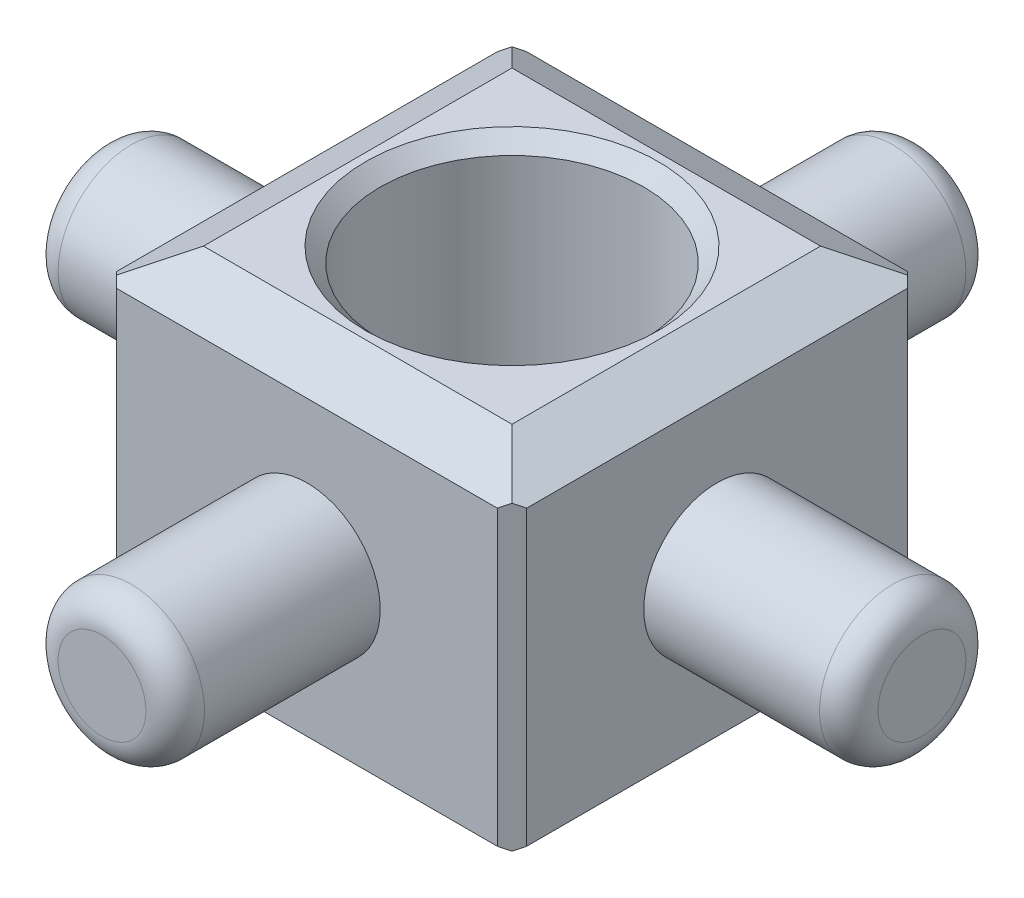
from build123d import *

# Parameters (mm, degrees)
SKETCH1_W                = 7
SKETCH1_H                = 7
EXTRUDE1_DEPTH           = 6
SKETCH2_R                = 2.25
CUT_EXTRUDE1_DEPTH       = 6
SKETCH3_R                = 1.25
EXTRUDE2_DEPTH           = 3.5
FILLET2_R                = 0.5
CIRPATTERN1_COUNT        = 4
FILLET2_OF_CIRPATTERN1_R = 0.5
CHAMFER1_SIZE            = 0.25
CHAMFER2_SIZE            = 0.5
CHAMFER2_SIZE2           = 0.866025404
CHAMFER2_PART_2_SIZE     = 0.5
CHAMFER2_PART_2_SIZE2    = 0.866025404
CHAMFER2_PART_3_SIZE     = 0.5
CHAMFER2_PART_3_SIZE2    = 0.866025404
CHAMFER2_PART_4_SIZE     = 0.5
CHAMFER2_PART_4_SIZE2    = 0.866025404


with BuildPart() as part:
    # Sketch1 → Extrude1 (new body)
    with BuildSketch(Plane(origin=(0, 0, 0), x_dir=(1, 0, 0), z_dir=(0, 1, 0))):
        Rectangle(SKETCH1_W, SKETCH1_H)
    extrude(amount=EXTRUDE1_DEPTH)

    # Sketch2 → Cut-Extrude1 (cut)
    with BuildSketch(Plane(origin=(0, 6, 0), x_dir=(1, 0, 0), z_dir=(0, 1, 0))):
        with Locations(Location((0, 0, 0), (0, 0, 270))):  # turned: the seam where the file's is
            Circle(SKETCH2_R)
    extrude(amount=-CUT_EXTRUDE1_DEPTH, mode=Mode.SUBTRACT)

    # Sketch3 → Extrude2 (add)
    with BuildSketch(Plane(origin=(3.5, 0, 0), x_dir=(0, 0, -1), z_dir=(1, 0, 0))):
        with Locations(Location((0, 3, 0), (0, 0, 180))):  # turned: the seam where the file's is
            Circle(SKETCH3_R)
    extrude2 = extrude(amount=EXTRUDE2_DEPTH)

    # Fillet2
    fillet2_edges = [part.edges().sort_by_distance(p)[0] for p in [
        (7, 3, -1.25),
    ]]
    fillet(fillet2_edges, radius=FILLET2_R)

    # CirPattern1: Extrude2 ×4 about axis
    cirpattern1_axis = Axis((0, 0, 0), (0, 1, 0))
    for i in range(1, CIRPATTERN1_COUNT):
        add(extrude2.rotate(cirpattern1_axis, i * 360 / CIRPATTERN1_COUNT))

    # Fillet2 of CirPattern1
    fillet2_of_cirpattern1_edges = [part.edges().sort_by_distance(p)[0] for p in [
        (-1.25, 3, -7),
        (-7, 3, 1.25),
        (1.25, 3, 7),
    ]]
    fillet(fillet2_of_cirpattern1_edges, radius=FILLET2_OF_CIRPATTERN1_R)

    # Chamfer1
    chamfer1_edges = [part.edges().sort_by_distance(p)[0] for p in [
        (0, 0, -2.25),
        (0, 6, -2.25),
        (-3.5, 3, -3.5),
        (3.5, 3, -3.5),
        (3.5, 3, 3.5),
        (-3.5, 3, 3.5),
    ]]
    chamfer(chamfer1_edges, length=CHAMFER1_SIZE)

    # Chamfer2
    chamfer2_edges = [part.edges().sort_by_distance(p)[0] for p in [
        (-3.5, 0, 0),
        (-3.5, 6, 0),
    ]]
    chamfer2_side = [part.faces().sort_by_distance(p)[0] for p in [
        (-3.5, 0.08845903, 0),
    ]]
    chamfer(chamfer2_edges, length=CHAMFER2_SIZE, length2=CHAMFER2_SIZE2, reference=chamfer2_side[0])

    # Chamfer2 part 2
    chamfer2_part_2_edges = [part.edges().sort_by_distance(p)[0] for p in [
        (0, 0, 3.5),
        (0, 6, 3.5),
    ]]
    chamfer2_part_2_side = [part.faces().sort_by_distance(p)[0] for p in [
        (0, 0.08845903, 3.5),
    ]]
    chamfer(chamfer2_part_2_edges, length=CHAMFER2_PART_2_SIZE, length2=CHAMFER2_PART_2_SIZE2, reference=chamfer2_part_2_side[0])

    # Chamfer2 part 3
    chamfer2_part_3_edges = [part.edges().sort_by_distance(p)[0] for p in [
        (3.5, 0, 0),
        (3.5, 6, 0),
    ]]
    chamfer2_part_3_side = [part.faces().sort_by_distance(p)[0] for p in [
        (3.5, 0.08845903, 0),
    ]]
    chamfer(chamfer2_part_3_edges, length=CHAMFER2_PART_3_SIZE, length2=CHAMFER2_PART_3_SIZE2, reference=chamfer2_part_3_side[0])

    # Chamfer2 part 4
    chamfer2_part_4_edges = [part.edges().sort_by_distance(p)[0] for p in [
        (0, 0, -3.5),
        (0, 6, -3.5),
    ]]
    chamfer2_part_4_side = [part.faces().sort_by_distance(p)[0] for p in [
        (0, 0.08845903, -3.5),
    ]]
    chamfer(chamfer2_part_4_edges, length=CHAMFER2_PART_4_SIZE, length2=CHAMFER2_PART_4_SIZE2, reference=chamfer2_part_4_side[0])


solid = part.part
